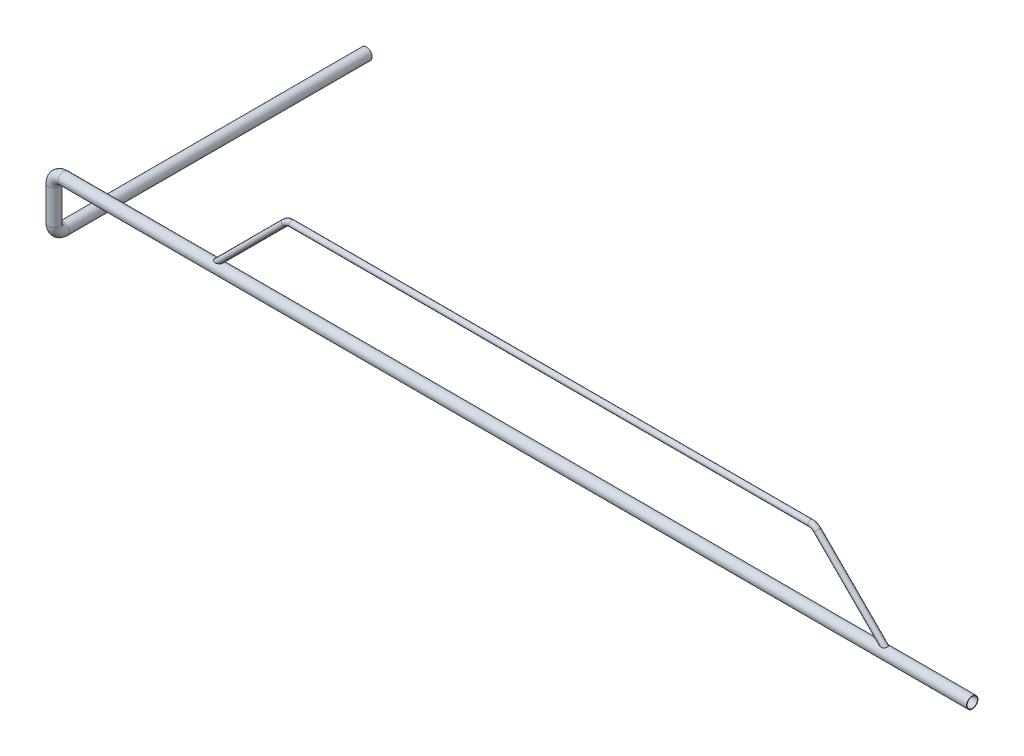
from build123d import *

# Parameters (mm, degrees)
SWEEP_THIN1_PROFILE_R   = 30
SWEEP_THIN1_PROFILE_R_2 = 27
SWEEP_THIN2_PROFILE_R   = 15
SWEEP_THIN2_PROFILE_R_2 = 12


with BuildPart() as part:
    # Sweep-Thin1: sweep along a curve in space
    with BuildLine() as sweep_thin1_path:
        Line((-24718.773163347, -8334.116301788, 40483.323546863), (-29492.905629752, -8334.116301788, 40483.323546863))
        ThreePointArc((-29542.905629752, -8384.116301788, 40483.323546863), (-29528.260968811, -8348.760962728, 40483.323546863), (-29492.905629752, -8334.116301788, 40483.323546863))
        Line((-29542.905629752, -8384.116301788, 40483.323546863), (-29542.905629752, -8564.527710935, 40483.323546863))
        ThreePointArc((-29542.905629752, -8564.527710935, 40483.323546863), (-29542.905629752, -8599.883049995, 40468.678885922), (-29542.905629752, -8614.527710935, 40433.323546863))
        Line((-29542.905629752, -8614.527710935, 40433.323546863), (-29542.905629752, -8614.527710935, 38842.113196056))
    # Sweep-Thin1 profile (on start of the path) → Sweep-Thin1 (sweep)
    with BuildSketch(Plane(origin=(-24718.773163347, -8334.116301788, 40483.323546863), x_dir=(0, 0, -1), z_dir=(-1, 0, 0))):
        Circle(SWEEP_THIN1_PROFILE_R)
        Circle(SWEEP_THIN1_PROFILE_R_2, mode=Mode.SUBTRACT)
    sweep(path=sweep_thin1_path.line)

    # Sweep-Thin2: sweep along a curve in space
    with BuildLine() as sweep_thin2_path:
        Line((-25155.275738285, -8334.116301788, 40483.323546863), (-25532.845010905, -7956.547029169, 40483.323546863))
        ThreePointArc((-25568.200349964, -7941.902368228, 40483.323546863), (-25549.066178346, -7945.708391602, 40483.323546863), (-25532.845010905, -7956.547029169, 40483.323546863))
        Line((-25568.200349964, -7941.902368228, 40483.323546863), (-28294.321997731, -7941.902368228, 40483.323546863))
        ThreePointArc((-28294.321997731, -7941.902368228, 40483.323546863), (-28313.45616935, -7945.708391602, 40483.323546863), (-28329.677336791, -7956.547029169, 40483.323546863))
        Line((-28329.677336791, -7956.547029169, 40483.323546863), (-28707.24660941, -8334.116301788, 40483.323546863))
    # Sweep-Thin2 profile (on start of the path) → Sweep-Thin2 (sweep)
    with BuildSketch(Plane(origin=(-25155.275738285, -8334.116301788, 40483.323546863), x_dir=(-0.7071067811865408, -0.7071067811865543, 0), z_dir=(-0.7071067811865543, 0.7071067811865408, -1.3626317981131553e-14))):
        Circle(SWEEP_THIN2_PROFILE_R)
        Circle(SWEEP_THIN2_PROFILE_R_2, mode=Mode.SUBTRACT)
    sweep(path=sweep_thin2_path.line)


solid = part.part
